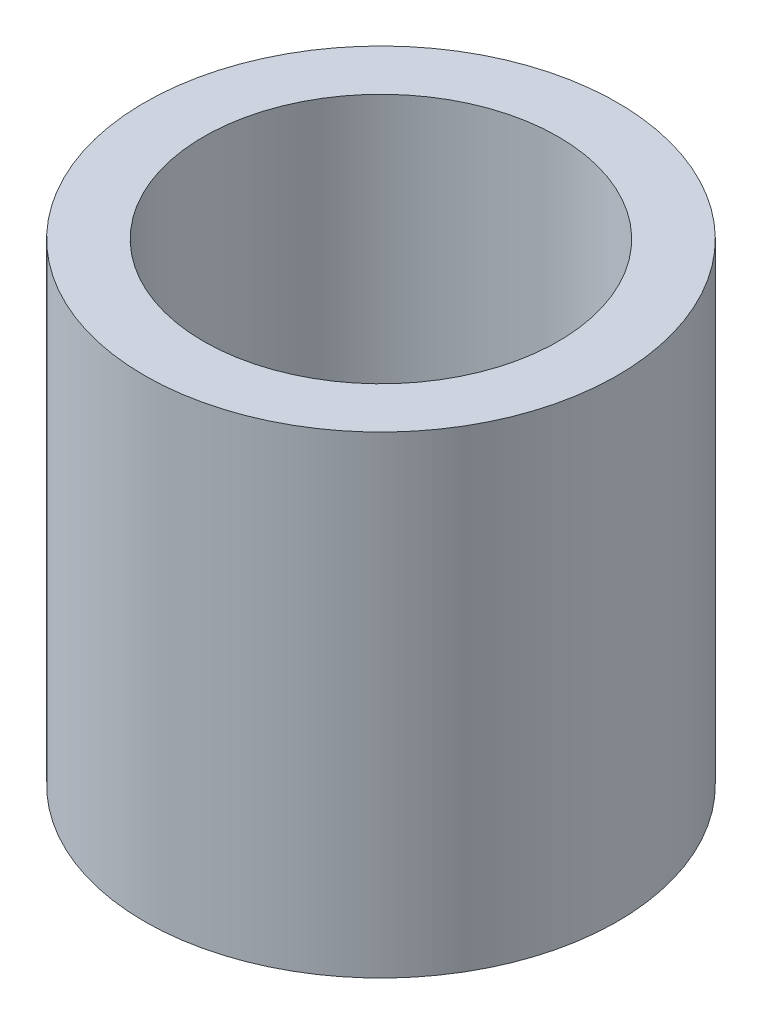
from build123d import *

# Parameters (mm, degrees)
SKETCH_2_R      = 10
SKETCH_2_R_2    = 7.5
EXTRUDE_1_DEPTH = 10


with BuildPart() as part:
    # 草图2 → 凸台-拉伸1 (new body, symmetric)
    with BuildSketch(Plane(origin=(0, 0, 0), x_dir=(1, 0, 0), z_dir=(0, 1, 0))):
        Circle(SKETCH_2_R)
        Circle(SKETCH_2_R_2, mode=Mode.SUBTRACT)
    extrude(amount=EXTRUDE_1_DEPTH, both=True)


solid = part.part
